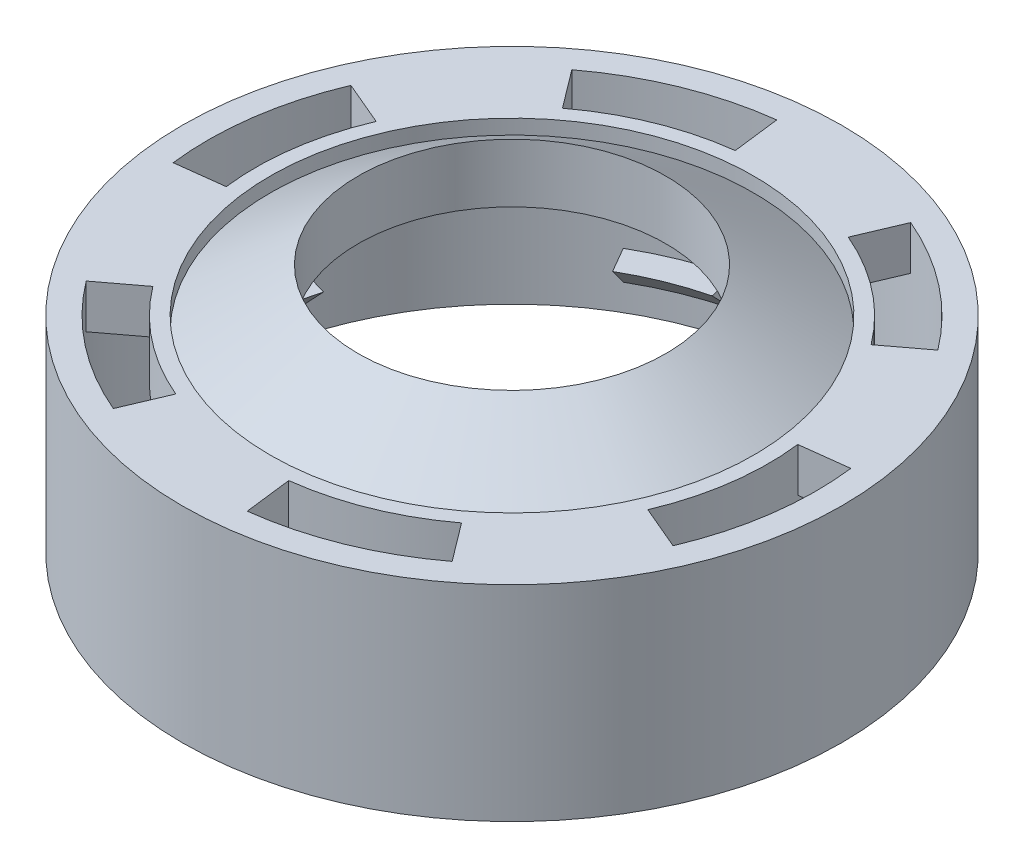
from build123d import *

# Parameters (mm, degrees)
SKETCH1_R          = 22.5
SKETCH1_R_2        = 20.75
EXTRUDE1_DEPTH     = 14
REVOLVE6_ANGLE     = 16
CIRPATTERN1_COUNT  = 6
SKETCH5_R          = 17.5
SKETCH5_R_2        = 16.5
EXTRUDE2_DEPTH     = 4
SKETCH7_R          = 10.5
SKETCH6_R          = 16.5
SKETCH8_R          = 10.5
CUT_EXTRUDE1_DEPTH = 18
EXTRUDE3_DEPTH     = 3
CIRPATTERN2_COUNT  = 6


with BuildPart() as part:
    # Sketch1 → Extrude1 (new body)
    with BuildSketch(Plane(origin=(0, 0, 0), x_dir=(1, 0, 0), z_dir=(0, 1, 0))):
        Circle(SKETCH1_R)
        Circle(SKETCH1_R_2, mode=Mode.SUBTRACT)
    extrude(amount=EXTRUDE1_DEPTH)

    # Sketch4 → Revolve6 (revolve)
    with BuildSketch(Plane.XY):
        Polygon((-20.75, 3.8), (-18.75, 3.8), (-20.75, 1.8), align=None)
    revolve6 = revolve(axis=Axis((0, 14, 0), (0, -1, 0)), revolution_arc=REVOLVE6_ANGLE)

    # CirPattern1: Revolve6 ×6 about axis
    cirpattern1_axis = Axis((0, 0, 0), (0, 1, 0))
    for i in range(1, CIRPATTERN1_COUNT):
        add(revolve6.rotate(cirpattern1_axis, i * 360 / CIRPATTERN1_COUNT))



with BuildPart() as body_2:
    # Sketch5 → Extrude2 (new body)
    with BuildSketch(Plane(origin=(0, 10, 0), x_dir=(-1, 0, 0), z_dir=(0, 1, 0))):
        Circle(SKETCH5_R)
        Circle(SKETCH5_R_2, mode=Mode.SUBTRACT)
    extrude(amount=EXTRUDE2_DEPTH)


with BuildPart() as body_3:
    # Sketch7 → Loft1 section 0
    with BuildSketch(Plane(origin=(0, 17, 0), x_dir=(-1, 0, 0), z_dir=(0, 1, 0))):
        Circle(SKETCH7_R)
    # Sketch6 → Loft1 section 1
    with BuildSketch(Plane(origin=(0, 13, 0), x_dir=(-1, 0, 0), z_dir=(0, 1, 0))):
        Circle(SKETCH6_R)
    loft()

    # Sketch8 → Cut-Extrude1 (cut, through all)
    with BuildSketch(Plane(origin=(0, 17, 0), x_dir=(-1, 0, 0), z_dir=(0, 1, 0))):
        Circle(SKETCH8_R)
    extrude(amount=-CUT_EXTRUDE1_DEPTH, mode=Mode.SUBTRACT)


with BuildPart() as part_1:
    add(part.part)

    add(body_2.part)  # Extrude3 merges body 2
    # Sketch9 → Extrude3 (add)
    with BuildSketch(Plane(origin=(0, 14, 0), x_dir=(-1, 0, 0), z_dir=(0, 1, 0))):
        with BuildLine():
            Line((2.528788876, -20.595332647), (2.13271351, -17.369557654))
            ThreePointArc((2.13271351, -17.369557654), (-2.435529267, -17.329691203), (-6.837794749, -16.108834935))
            Line((-6.837794749, -16.108834935), (-8.107670916, -19.100475709))
            ThreePointArc((-8.107670916, -19.100475709), (-2.887841845, -20.548062426), (2.528788876, -20.595332647))
        make_face()
    extrude3 = extrude(amount=-EXTRUDE3_DEPTH)

    # CirPattern2: Extrude3 ×6 about axis
    cirpattern2_axis = Axis((0, 0, 0), (0, 1, 0))
    for i in range(1, CIRPATTERN2_COUNT):
        add(extrude3.rotate(cirpattern2_axis, i * 360 / CIRPATTERN2_COUNT))


solid = Compound([body_3.part, part_1.part])
